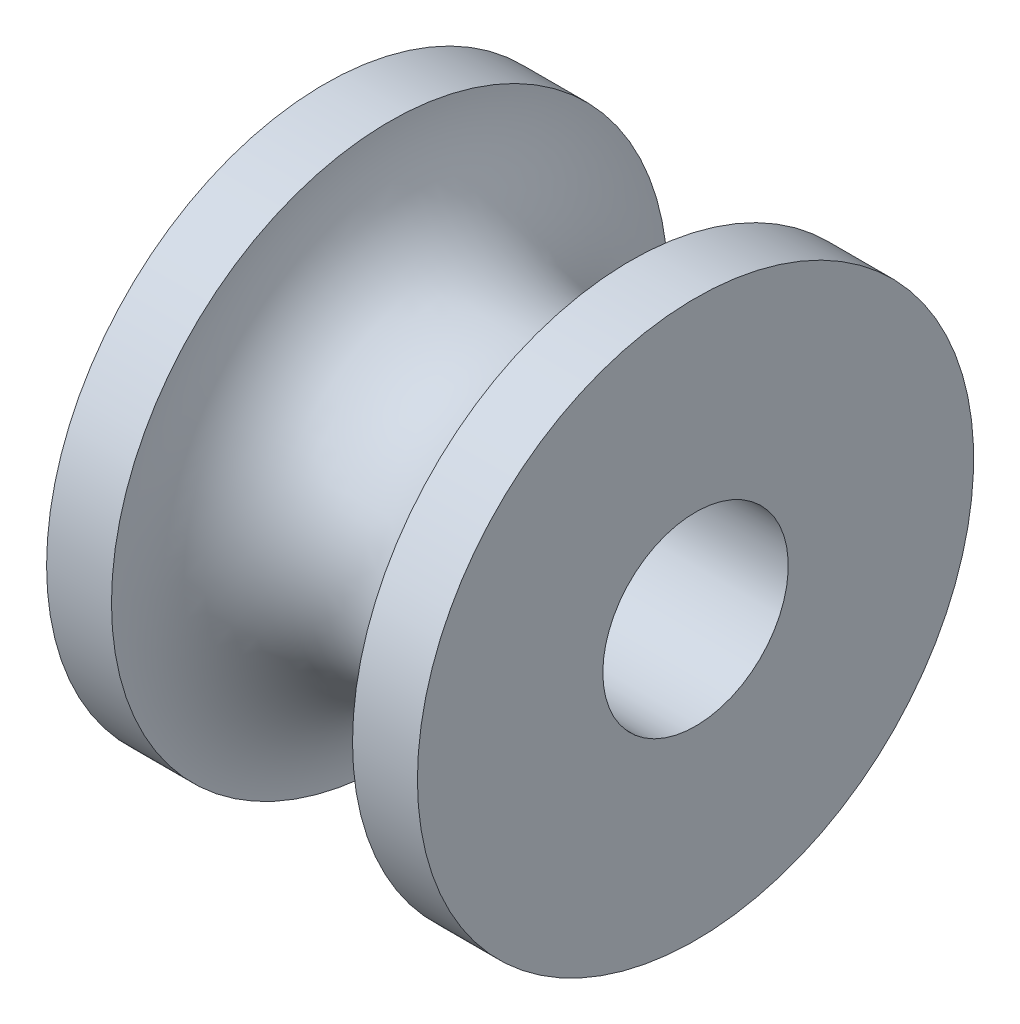
from build123d import *


with BuildPart() as part:
    # Esquisse2 → Révolution1 (revolve)
    with BuildSketch(Plane.XY):
        with BuildLine():
            Line((-4, -6), (-2.6, -6))
            ThreePointArc((-2.6, -6), (0, -3.4), (2.6, -6))
            Line((2.6, -6), (4, -6))
            Line((4, -6), (4, -2))
            Line((4, -2), (-4, -2))
            Line((-4, -2), (-4, -6))
        make_face()
    revolve(axis=Axis((-9.599452589, 0, 0), (1, 0, 0)))


solid = part.part
